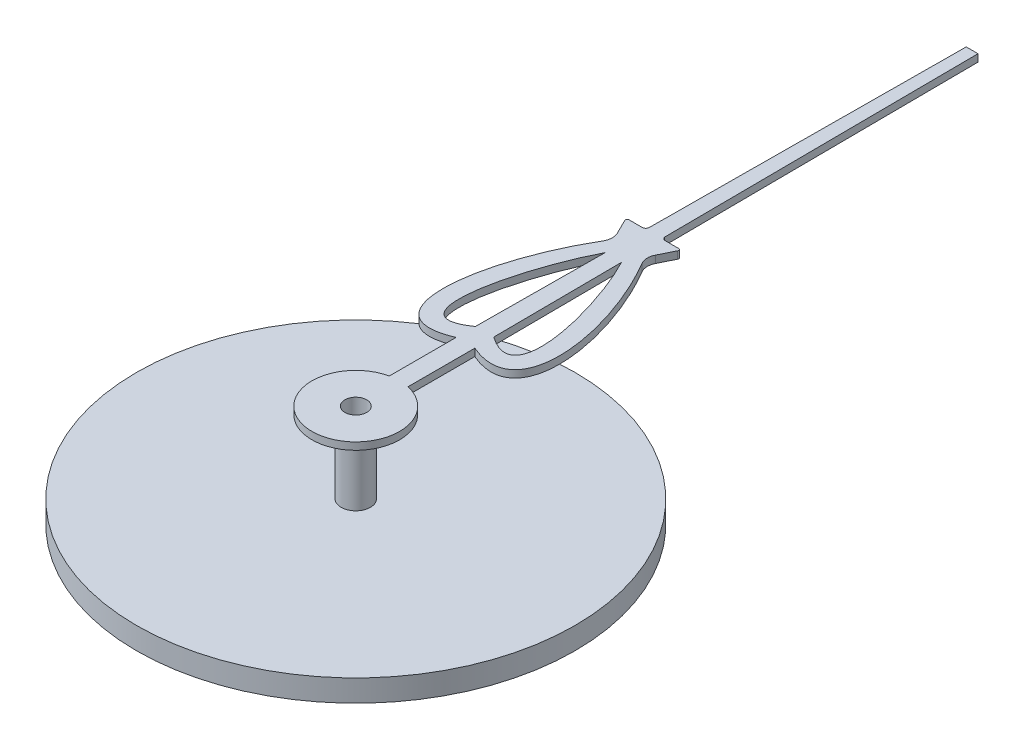
from build123d import *

# Parameters (mm, degrees)
BOSS_EXTRUDE1_DEPTH = 0.1
SKETCH2_R           = 0.2
BOSS_EXTRUDE2_DEPTH = 1
SKETCH3_R           = 3
BOSS_EXTRUDE3_DEPTH = 0.3
SKETCH4_R           = 0.15
CUT_EXTRUDE1_DEPTH  = 2.4


with BuildPart() as part:
    # Sketch1 → Boss-Extrude1 (new body)
    with BuildSketch(Plane(origin=(0, 0, 0), x_dir=(1, 0, 0), z_dir=(0, 1, 0))):
        with BuildLine():
            Line((-0.127585763, 0.586277983), (-0.127585763, 1.500996355))
            add(Edge.make_bspline(
                [(-0.127585763, 1.500996355), (-0.613609966, 1.292745221), (-0.997428455, 1.836597424), (-0.58121193, 3.118510404), (-0.267201121, 3.648320045)],
                knots=[0, 0, 0, 0, 0.463523694, 0.927047389, 0.927047389, 0.927047389, 0.927047389], degree=3))
            ThreePointArc((-0.267201121, 3.648320045), (-0.239390751, 3.74285385), (-0.260097073, 3.83919338))
            Line((-0.260097073, 3.83919338), (-0.359543258, 4.039599684))
            ThreePointArc((-0.359543258, 4.039599684), (-0.36190456, 4.065500923), (-0.338780115, 4.077405124))
            Line((-0.338780115, 4.077405124), (-0.157398308, 4.077405124))
            ThreePointArc((-0.157398308, 4.077405124), (-0.122926977, 4.092023881), (-0.108734749, 4.126672999))
            Line((-0.108734749, 4.126672999), (-0.080541531, 8.433581196))
            Line((-0.080541531, 8.433581196), (0.080699272, 8.433581196))
            Line((0.080699272, 8.433581196), (0.109905863, 4.115918774))
            ThreePointArc((0.109905863, 4.115918774), (0.126940207, 4.088385312), (0.157398308, 4.077405124))
            Line((0.157398308, 4.077405124), (0.338780115, 4.077405124))
            ThreePointArc((0.338780115, 4.077405124), (0.36190456, 4.065500923), (0.359543258, 4.039599684))
            Line((0.359543258, 4.039599684), (0.260097073, 3.83919338))
            ThreePointArc((0.260097073, 3.83919338), (0.239390751, 3.74285385), (0.267201121, 3.648320045))
            add(Edge.make_bspline(
                [(0.127585763, 1.500996355), (1.09963417, 1.084494086), (0.895222739, 2.588700762), (0.267201121, 3.648320045)],
                knots=[0, 0, 0, 0, 0.927047389, 0.927047389, 0.927047389, 0.927047389], degree=3))
            Line((0.127585763, 1.500996355), (0.127585763, 0.586277983))
            ThreePointArc((0.127585763, 0.586277983), (0, -0.6), (-0.127585763, 0.586277983))
        make_face()
        with BuildLine():
            Line((0.113918239, 3.522473584), (0.125824318, 1.761520463))
            add(Edge.make_bspline(
                [(0.125824318, 1.761520463), (0.890796605, 1.231501017), (0.501435582, 2.785705467), (0.113918239, 3.522473584)],
                knots=[0.044229807, 0.044229807, 0.044229807, 0.044229807, 0.913901264, 0.913901264, 0.913901264, 0.913901264], degree=3))
        make_face(mode=Mode.SUBTRACT)
        with BuildLine():
            Line((-0.113060898, 3.524102277), (-0.125714788, 1.761596361))
            add(Edge.make_bspline(
                [(-0.125714788, 1.761596361), (-0.891397992, 1.23096165), (-0.500879166, 2.787963848), (-0.113060898, 3.524102277)],
                knots=[0.044188303, 0.044188303, 0.044188303, 0.044188303, 0.914542619, 0.914542619, 0.914542619, 0.914542619], degree=3))
        make_face(mode=Mode.SUBTRACT)
    extrude(amount=BOSS_EXTRUDE1_DEPTH)

    # Sketch2 → Boss-Extrude2 (add)
    with BuildSketch(Plane.XZ):
        Circle(SKETCH2_R)
    extrude(amount=BOSS_EXTRUDE2_DEPTH)

    # Sketch3 → Boss-Extrude3 (add)
    with BuildSketch(Plane.XZ.offset(1)):
        Circle(SKETCH3_R)
    extrude(amount=BOSS_EXTRUDE3_DEPTH)

    # Sketch4 → Cut-Extrude1 (cut, through all)
    with BuildSketch(Plane(origin=(0, 0.1, 0), x_dir=(1, 0, 0), z_dir=(0, 1, 0))):
        Circle(SKETCH4_R)
    extrude(amount=-CUT_EXTRUDE1_DEPTH, mode=Mode.SUBTRACT)


solid = part.part
